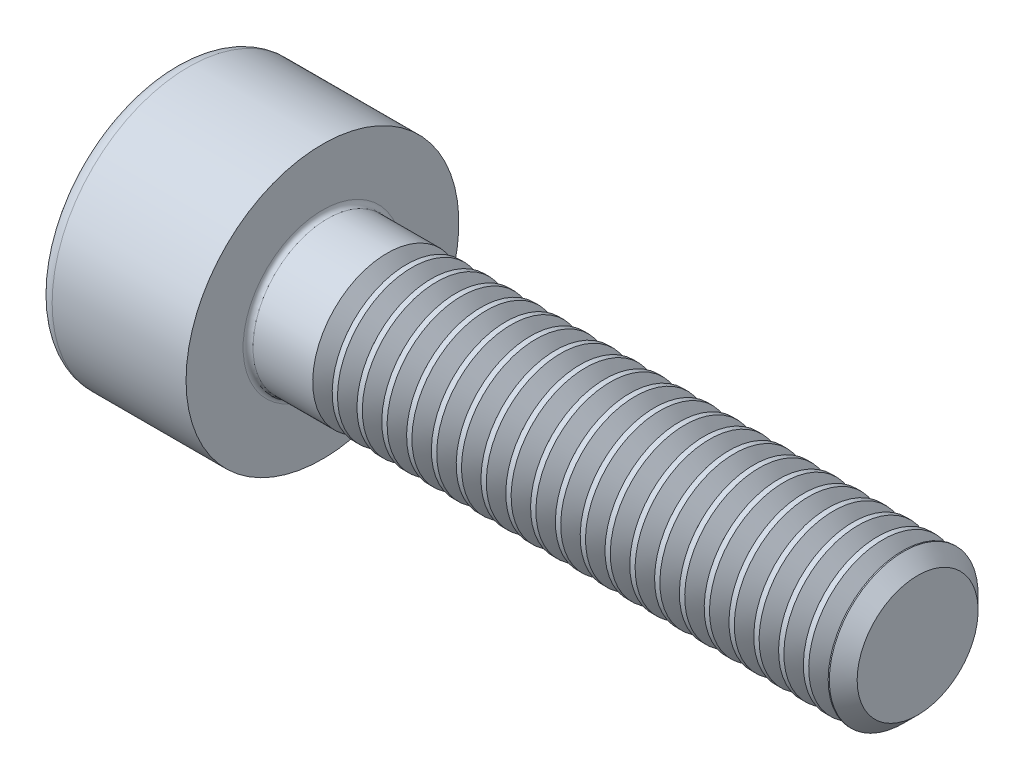
from build123d import *

# Parameters (mm, degrees)
FILLET1_R       = 0.1
FILLET2_R       = 0.3
HEX_2_DEPTH     = 1.3
THDSCHPAT_COUNT = 21
THDSCHPAT_PITCH = 0.5


with BuildPart() as part:
    # BodySke → Base-Revolve (revolve)
    with BuildSketch(Plane.XY, mode=Mode.PRIVATE) as base_revolve_sk:
        Polygon((0, 0), (0, 2.75), (3, 2.75), (3, 1.5), (14.7195, 1.5), (15, 1.2195), (15, 0), align=None)
    revolve(base_revolve_sk.sketch.rotate(Axis((-31.75, 0, 0), (1, 0, 0)), 90), axis=Axis((-31.75, 0, 0), (1, 0, 0)))  # turned: the seam where the file's is

    # Fillet1
    fillet1_edges = [part.edges().sort_by_distance(p)[0] for p in [
        (3, 0, -1.5),
    ]]
    fillet(fillet1_edges, radius=FILLET1_R)

    # Fillet2
    fillet2_edges = [part.edges().sort_by_distance(p)[0] for p in [
        (0, 0, -2.75),
    ]]
    fillet(fillet2_edges, radius=FILLET2_R)

    # Sketch2 → Hex-PreBroach (revolve, cut)
    with BuildSketch(Plane.XY, mode=Mode.PRIVATE) as hex_prebroach_sk:
        Polygon((0, 1.26), (1.3, 1.26), (2.027461339, 0), (0, 0), align=None)
    revolve(hex_prebroach_sk.sketch.rotate(Axis((0, 0, 0), (1, 0, 0)), 90), axis=Axis((0, 0, 0), (1, 0, 0)), mode=Mode.SUBTRACT)  # turned: the seam where the file's is

    # Sketch3 → Hex 2 (cut)
    with BuildSketch(Plane(origin=(0, 0, 0), x_dir=(0, 0.5, 0.866025404), z_dir=(-1, 0, 0))):
        Polygon((0.727461339, 1.26), (-0.727461339, 1.26), (-1.454922678, 0), (-0.727461339, -1.26), (0.727461339, -1.26), (1.454922678, 0), align=None)
    extrude(amount=-HEX_2_DEPTH, mode=Mode.SUBTRACT)

    # ThdSchSke → ThreadSchematic (revolve, cut)
    with BuildSketch(Plane.XY, mode=Mode.PRIVATE) as threadschematic_sk:
        Polygon((4.5, -1.2195), (4.303591786, -1.5), (4.303591786, -1.875), (4.696408214, -1.875), (4.696408214, -1.5), align=None)
    threadschematic = revolve(threadschematic_sk.sketch.rotate(Axis((-3.175, 0, 0), (1, 0, 0)), 270), axis=Axis((-3.175, 0, 0), (1, 0, 0)), mode=Mode.SUBTRACT)  # turned: the seam where the file's is

    # ThdSchPat: ThreadSchematic ×21
    with Locations(*[(i * THDSCHPAT_PITCH, 0, 0) for i in range(1, THDSCHPAT_COUNT)]):
        add(threadschematic, mode=Mode.SUBTRACT)


solid = part.part
